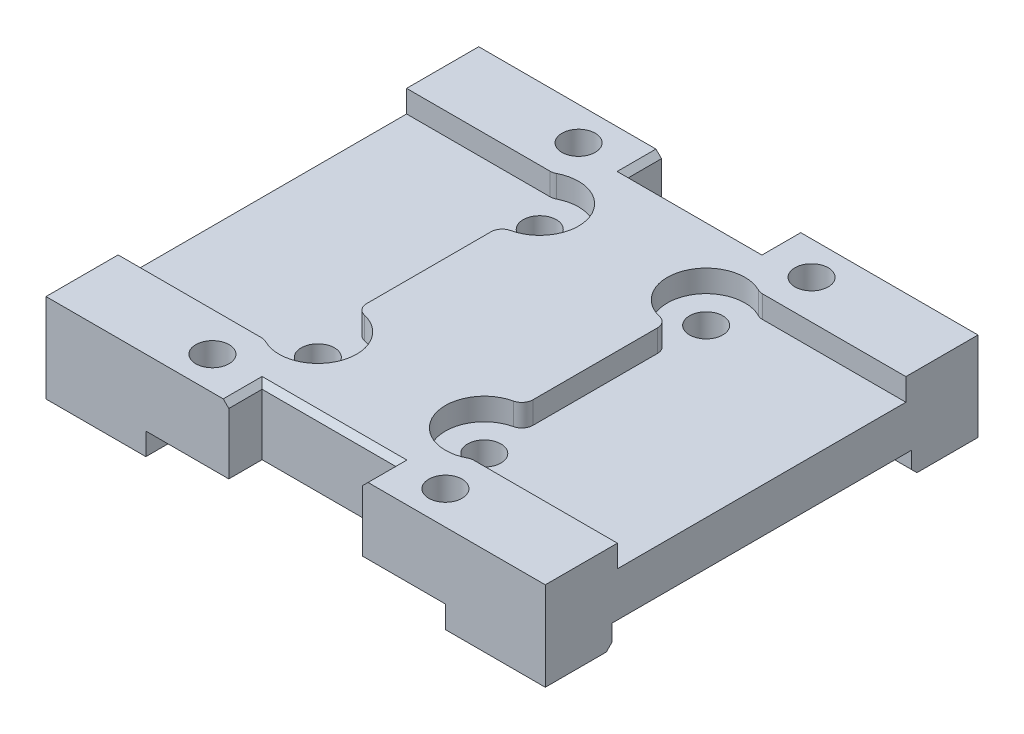
from build123d import *

# Parameters (mm, degrees)
SKETCH_2_W                = 45
SKETCH_2_H                = 33
SKETCH_2_R                = 1.5
EXTRUDE_1_DEPTH           = 6
SKETCH_3_W                = 45
SKETCH_3_H                = 3
EXTRUDE_2_DEPTH           = 2
SKETCH_4_R                = 3.5
CUT_EXTRUDE_1_DEPTH       = 2
SKETCH_11_W               = 45
SKETCH_11_H               = 3
EXTRUDE_4_DEPTH           = 8
CUT_EXTRUDE_2_REACH       = 10
SKETCH_9_W                = 12.05
SKETCH_9_H                = 3
CHAMFER_1_SIZE            = 0.5
SKETCH_19_W               = 6
SKETCH_19_H               = 6
CUT_EXTRUDE_4_DEPTH       = 2
HOLE_WIZARD_3_0_3_1_D     = 3
HOLE_WIZARD_3_0_3_1_DEPTH = 6.001
CHAMFER_2_SIZE            = 0.5
SKETCH_20_W               = 15
SKETCH_20_H               = 26
CUT_EXTRUDE_5_DEPTH       = 2
FILLET_1_R                = 1
SKETCH_22_W               = 15
SKETCH_22_H               = 6
CUT_EXTRUDE_6_DEPTH       = 2


with BuildPart() as part:
    # 草图2 → 凸台-拉伸1 (new body)
    with BuildSketch(Plane(origin=(0, 0, 0), x_dir=(1, 0, 0), z_dir=(0, 1, 0))):
        Rectangle(SKETCH_2_W, SKETCH_2_H)
        with Locations((-7.5, 10)):
            Circle(SKETCH_2_R, mode=Mode.SUBTRACT)
        with Locations((7.5, 10)):
            Circle(SKETCH_2_R, mode=Mode.SUBTRACT)
        with Locations((-7.5, -10)):
            Circle(SKETCH_2_R, mode=Mode.SUBTRACT)
        with Locations((7.5, -10)):
            Circle(SKETCH_2_R, mode=Mode.SUBTRACT)
    extrude(amount=EXTRUDE_1_DEPTH)

    # 草图3 → 凸台-拉伸2 (add)
    with BuildSketch(Plane.XZ):
        with Locations((0, -15)):
            Rectangle(SKETCH_3_W, SKETCH_3_H)
        with Locations((0, 15)):
            Rectangle(SKETCH_3_W, SKETCH_3_H)
    extrude(amount=EXTRUDE_2_DEPTH)

    # 草图4 → 切除-拉伸1 (cut)
    with BuildSketch(Plane(origin=(0, 6, 0), x_dir=(1, 0, 0), z_dir=(0, 1, 0))):
        with Locations((-7.5, 10)):
            Circle(SKETCH_4_R)
        with Locations((7.5, 10)):
            Circle(SKETCH_4_R)
        with Locations((7.5, -10)):
            Circle(SKETCH_4_R)
        with Locations((-7.5, -10)):
            Circle(SKETCH_4_R)
    extrude(amount=-CUT_EXTRUDE_1_DEPTH, mode=Mode.SUBTRACT)

    # 草图11 → 凸台-拉伸4 (add)
    with BuildSketch(Plane(origin=(0, 6, 0), x_dir=(1, 0, 0), z_dir=(0, 1, 0))):
        with Locations((0, 18)):
            Rectangle(SKETCH_11_W, SKETCH_11_H)
        with Locations((0, -18)):
            Rectangle(SKETCH_11_W, SKETCH_11_H)
    extrude(amount=-EXTRUDE_4_DEPTH)

    # 草图9 → 切除-拉伸2 (cut, up to next)
    with BuildSketch(Plane(origin=(0, 6, 0), x_dir=(1, 0, 0), z_dir=(0, 1, 0)), mode=Mode.PRIVATE) as cut_extrude_2_sk1:
        with Locations((0, 18)):
            Rectangle(SKETCH_9_W, SKETCH_9_H)
    cut_extrude_2_tool1 = extrude(cut_extrude_2_sk1.sketch, amount=-CUT_EXTRUDE_2_REACH, mode=Mode.PRIVATE) & part.part
    add(cut_extrude_2_tool1.solids().sort_by_distance((0, 6, -18))[0], mode=Mode.SUBTRACT)
    # 草图9 → 切除-拉伸2 (cut, up to next)
    with BuildSketch(Plane(origin=(0, 6, 0), x_dir=(1, 0, 0), z_dir=(0, 1, 0)), mode=Mode.PRIVATE) as cut_extrude_2_sk2:
        with Locations((0, -18)):
            Rectangle(SKETCH_9_W, SKETCH_9_H)
    cut_extrude_2_tool2 = extrude(cut_extrude_2_sk2.sketch, amount=-CUT_EXTRUDE_2_REACH, mode=Mode.PRIVATE) & part.part
    add(cut_extrude_2_tool2.solids().sort_by_distance((0, 6, 18))[0], mode=Mode.SUBTRACT)

    # 倒角1
    chamfer_1_edges = [part.edges().sort_by_distance(p)[0] for p in [
        (-6.025, 6, -18),
        (0, 6, -16.5),
        (6.025, 6, -18),
        (6.025, 6, 18),
        (0, 6, 16.5),
        (-6.025, 6, 18),
    ]]
    chamfer(chamfer_1_edges, length=CHAMFER_1_SIZE)

    # 草图15 → M3 螺纹孔2 (revolve, cut)
    with BuildSketch(Plane(origin=(-17.5, -2, -16.5), x_dir=(0, 0, -1), z_dir=(1, 0, 0))):
        Polygon((0, 0), (0, 4.690989712), (1.15, 4), (1.15, 0), align=None)
    hole_wizard_m3_2 = revolve(axis=Axis((-17.5, -8.35, -16.5), (0, 1, 0)), mode=Mode.SUBTRACT)

    # 草图17 → M3 螺纹孔3 (revolve, cut)
    with BuildSketch(Plane(origin=(17.5, -2, -16.5), x_dir=(0, 0, -1), z_dir=(1, 0, 0))):
        Polygon((0, 0), (0, 4.690989712), (1.15, 4), (1.15, 0), align=None)
    hole_wizard_m3_3 = revolve(axis=Axis((17.5, -8.35, -16.5), (0, 1, 0)), mode=Mode.SUBTRACT)

    # 草图19 → 切除-拉伸4 (cut)
    with BuildSketch(Plane.XZ.offset(2)):
        with Locations((-10.5, -16.5)):
            Rectangle(SKETCH_19_W, SKETCH_19_H)
        with Locations((10.5, -16.5)):
            Rectangle(SKETCH_19_W, SKETCH_19_H)
    cut_extrude_4 = extrude(amount=-CUT_EXTRUDE_4_DEPTH, mode=Mode.SUBTRACT)

    # Ø3.0 (3) 直径孔1
    with Locations(Plane.XZ):
        with Locations((-10.5, -16.5), (10.5, -16.5)):
            hole_wizard_3_0_3_1 = Hole(HOLE_WIZARD_3_0_3_1_D / 2, depth=HOLE_WIZARD_3_0_3_1_DEPTH)

    # 镜向1: M3 螺纹孔2, M3 螺纹孔3, 切除-拉伸4, Ø3.0 (3) 直径孔1 across plane
    add(hole_wizard_m3_2.mirror(Plane.XY), mode=Mode.SUBTRACT)
    add(hole_wizard_m3_3.mirror(Plane.XY), mode=Mode.SUBTRACT)
    add(cut_extrude_4.mirror(Plane.XY), mode=Mode.SUBTRACT)
    add(hole_wizard_3_0_3_1.mirror(Plane.XY), mode=Mode.SUBTRACT)

    # 倒角2
    chamfer_2_edges = [part.edges().sort_by_distance(p)[0] for p in [
        (-18, -2, -13.5),
        (0, -2, -13.5),
        (0, -2, 13.5),
        (18, -2, 13.5),
        (18, -2, -13.5),
        (-18, -2, 13.5),
    ]]
    chamfer(chamfer_2_edges, length=CHAMFER_2_SIZE)

    # 草图20 → 切除-拉伸5 (cut)
    with BuildSketch(Plane(origin=(0, 6, 0), x_dir=(1, 0, 0), z_dir=(0, 1, 0))):
        with Locations((15, 0)):
            Rectangle(SKETCH_20_W, SKETCH_20_H)
        with Locations((-15, 0)):
            Rectangle(SKETCH_20_W, SKETCH_20_H)
    extrude(amount=-CUT_EXTRUDE_5_DEPTH, mode=Mode.SUBTRACT)

    # 圆角1
    fillet_1_edges = [part.edges().sort_by_distance(p)[0] for p in [
        (9.302775638, 5, 13),
        (7.5, 5, 6.5),
        (7.5, 5, -6.5),
        (9.302775638, 5, -13),
        (-9.302775638, 5, -13),
        (-7.5, 5, -6.5),
        (-7.5, 5, 6.5),
        (-9.302775638, 5, 13),
    ]]
    fillet(fillet_1_edges, radius=FILLET_1_R)

    # 草图22 → 切除-拉伸6 (cut)
    with BuildSketch(Plane.XZ.offset(2)):
        with Locations((0, 16.5)):
            Rectangle(SKETCH_22_W, SKETCH_22_H)
        with Locations((0, -16.5)):
            Rectangle(SKETCH_22_W, SKETCH_22_H)
    extrude(amount=-CUT_EXTRUDE_6_DEPTH, mode=Mode.SUBTRACT)


solid = part.part
